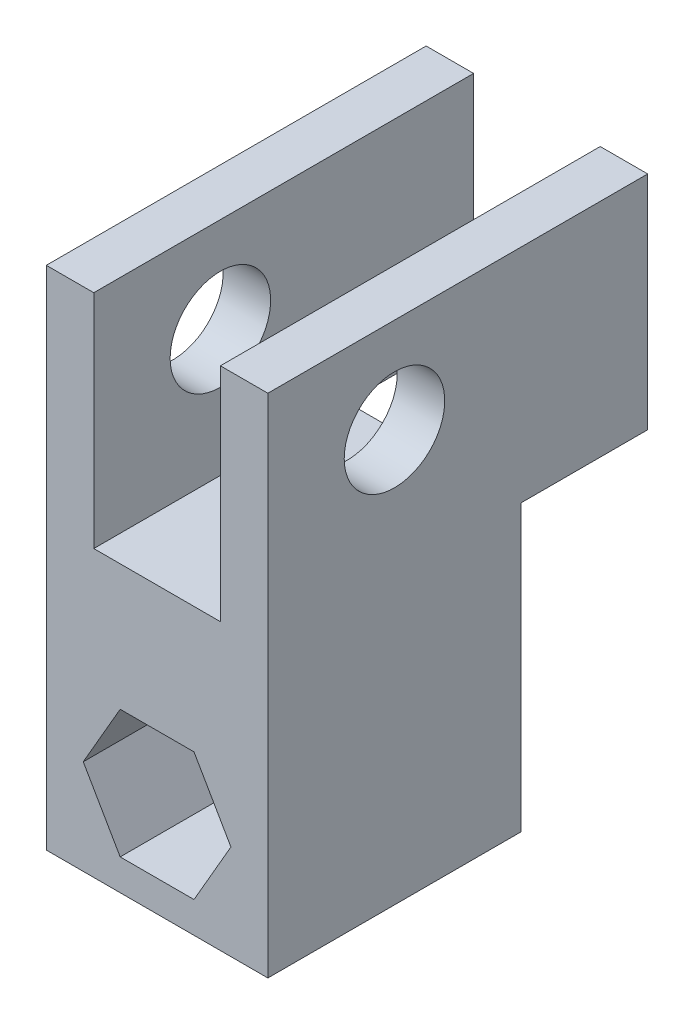
from build123d import *

# Parameters (mm, degrees)
BOSS_EXTRUDE1_DEPTH     = 25.4
CUT_EXTRUDE1_DEPTH      = 26.4
F_3_8_CLEARANCE_HOLE1_D = 10.0838
SKETCH7_W               = 4.7625
SKETCH7_H               = 22.225
BOSS_EXTRUDE2_DEPTH     = 12.7


with BuildPart() as part:
    # Sketch1 → Boss-Extrude1 (new body)
    with BuildSketch(Plane.XY):
        Polygon((-11.1125, 0), (11.1125, 0), (11.1125, 50.8), (6.35, 50.8), (6.35, 28.575), (-6.35, 28.575), (-6.35, 50.8), (-11.1125, 50.8), align=None)
    extrude(amount=BOSS_EXTRUDE1_DEPTH)

    # Sketch2 → Cut-Extrude1 (cut, through all)
    with BuildSketch(Plane.XY.offset(25.4)):
        Polygon((3.702835951, 15.9385), (-3.702835951, 15.9385), (-7.405671903, 9.525), (-3.702835951, 3.1115), (3.702835951, 3.1115), (7.405671903, 9.525), align=None)
    extrude(amount=-CUT_EXTRUDE1_DEPTH, mode=Mode.SUBTRACT)

    # 3/8 Clearance Hole1 (through all)
    with Locations(Plane.ZY.offset(11.1125)):
        with Locations((12.7, 41.275)):
            Hole(F_3_8_CLEARANCE_HOLE1_D / 2)

    # Sketch7 → Boss-Extrude2 (add)
    with BuildSketch(Plane(origin=(0, 0, 0), x_dir=(-1, 0, 0), z_dir=(0, 0, -1))):
        with Locations((-8.73125, 39.6875)):
            Rectangle(SKETCH7_W, SKETCH7_H)
        with Locations((8.73125, 39.6875)):
            Rectangle(SKETCH7_W, SKETCH7_H)
    extrude(amount=BOSS_EXTRUDE2_DEPTH)


solid = part.part
